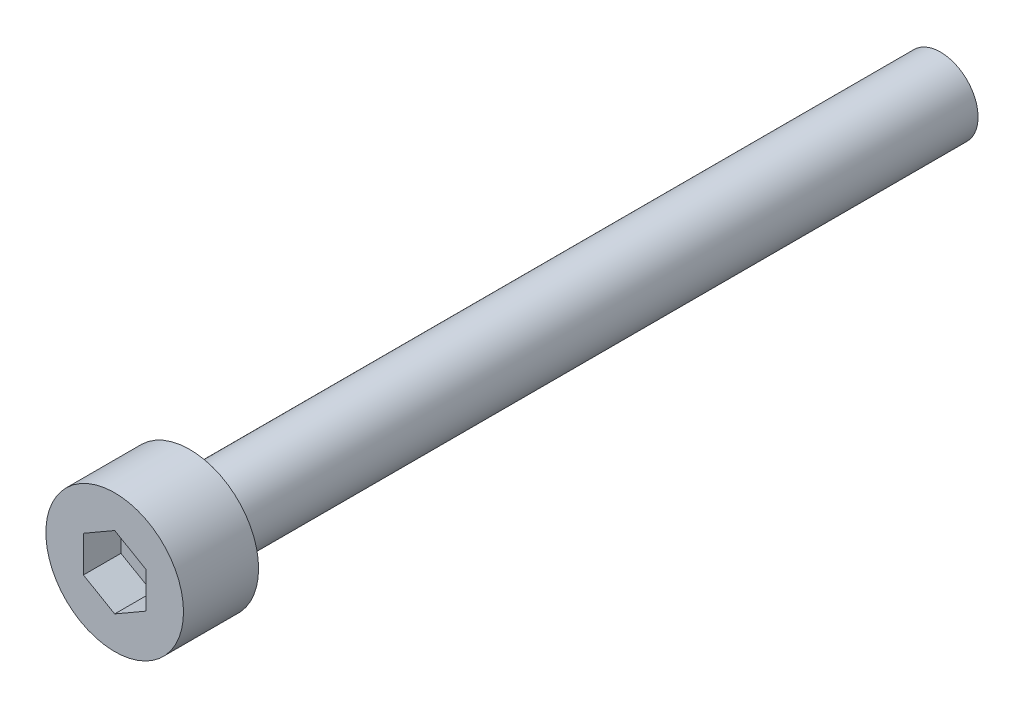
from build123d import *

# Parameters (mm, degrees)
SKETCH_1_R          = 2.75
EXTRUDE_1_DEPTH     = 3
CUT_EXTRUDE_1_DEPTH = 1.5
SKETCH_3_R          = 1.5
EXTRUDE_2_DEPTH     = 30


with BuildPart() as part:
    # 草图1 → 凸台-拉伸1 (new body)
    with BuildSketch(Plane.XY):
        Circle(SKETCH_1_R)
    extrude(amount=EXTRUDE_1_DEPTH)

    # 草图2 → 切除-拉伸1 (cut)
    with BuildSketch(Plane.XY.offset(3)):
        Polygon((0, -1.443375673), (1.25, -0.721687836), (1.25, 0.721687836), (0, 1.443375673), (-1.25, 0.721687836), (-1.25, -0.721687836), align=None)
    extrude(amount=-CUT_EXTRUDE_1_DEPTH, mode=Mode.SUBTRACT)

    # 草图3 → 凸台-拉伸2 (add)
    with BuildSketch(Plane(origin=(0, 0, 0), x_dir=(-1, 0, 0), z_dir=(0, 0, -1))):
        Circle(SKETCH_3_R)
    extrude(amount=EXTRUDE_2_DEPTH)


solid = part.part
